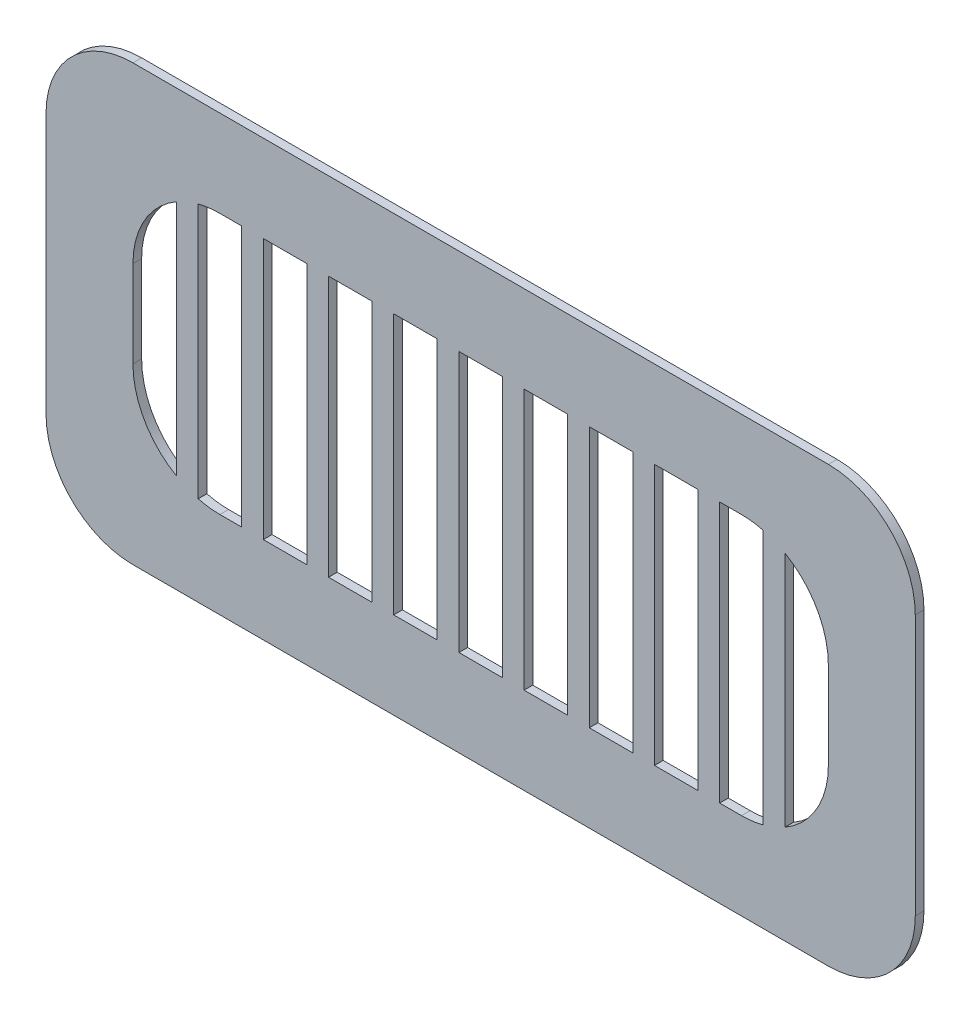
from build123d import *

# Parameters (mm, degrees)
BOSS_EXTRUDE1_DEPTH = 1
SKETCH3_W           = 2.5
SKETCH3_H           = 30
BOSS_EXTRUDE2_DEPTH = 1


with BuildPart() as part:
    # Sketch1 → Boss-Extrude1 (new body)
    with BuildSketch(Plane.XY):
        with BuildLine():
            Line((-40, 25), (40, 25))
            ThreePointArc((40, 25), (47.071067812, 22.071067812), (50, 15))
            Line((50, 15), (50, -15))
            ThreePointArc((50, -15), (47.071067812, -22.071067812), (40, -25))
            Line((40, -25), (-40, -25))
            ThreePointArc((-40, -25), (-47.071067812, -22.071067812), (-50, -15))
            Line((-50, -15), (-50, 15))
            ThreePointArc((-50, 15), (-47.071067812, 22.071067812), (-40, 25))
        make_face()
        with BuildLine():
            Line((-30, 15), (30, 15))
            ThreePointArc((30, 15), (37.071067812, 12.071067812), (40, 5))
            Line((40, 5), (40, -5))
            ThreePointArc((40, -5), (37.071067812, -12.071067812), (30, -15))
            Line((30, -15), (-30, -15))
            ThreePointArc((-30, -15), (-37.071067812, -12.071067812), (-40, -5))
            Line((-40, -5), (-40, 5))
            ThreePointArc((-40, 5), (-37.071067812, 12.071067812), (-30, 15))
        make_face(mode=Mode.SUBTRACT)
    extrude(amount=BOSS_EXTRUDE1_DEPTH)

    # Sketch3 → Boss-Extrude2 (add)
    with BuildSketch(Plane.XY.offset(1)):
        with Locations((-33.75, 0)):
            Rectangle(SKETCH3_W, SKETCH3_H)
        with Locations((-26.25, 0)):
            Rectangle(SKETCH3_W, SKETCH3_H)
        with Locations((-18.75, 0)):
            Rectangle(SKETCH3_W, SKETCH3_H)
        with Locations((-11.25, 0)):
            Rectangle(SKETCH3_W, SKETCH3_H)
        with Locations((-3.75, 0)):
            Rectangle(SKETCH3_W, SKETCH3_H)
        with Locations((3.75, 0)):
            Rectangle(SKETCH3_W, SKETCH3_H)
        with Locations((11.25, 0)):
            Rectangle(SKETCH3_W, SKETCH3_H)
        with Locations((18.75, 0)):
            Rectangle(SKETCH3_W, SKETCH3_H)
        with Locations((26.25, 0)):
            Rectangle(SKETCH3_W, SKETCH3_H)
        with Locations((33.75, 0)):
            Rectangle(SKETCH3_W, SKETCH3_H)
    extrude(amount=-BOSS_EXTRUDE2_DEPTH)


solid = part.part
